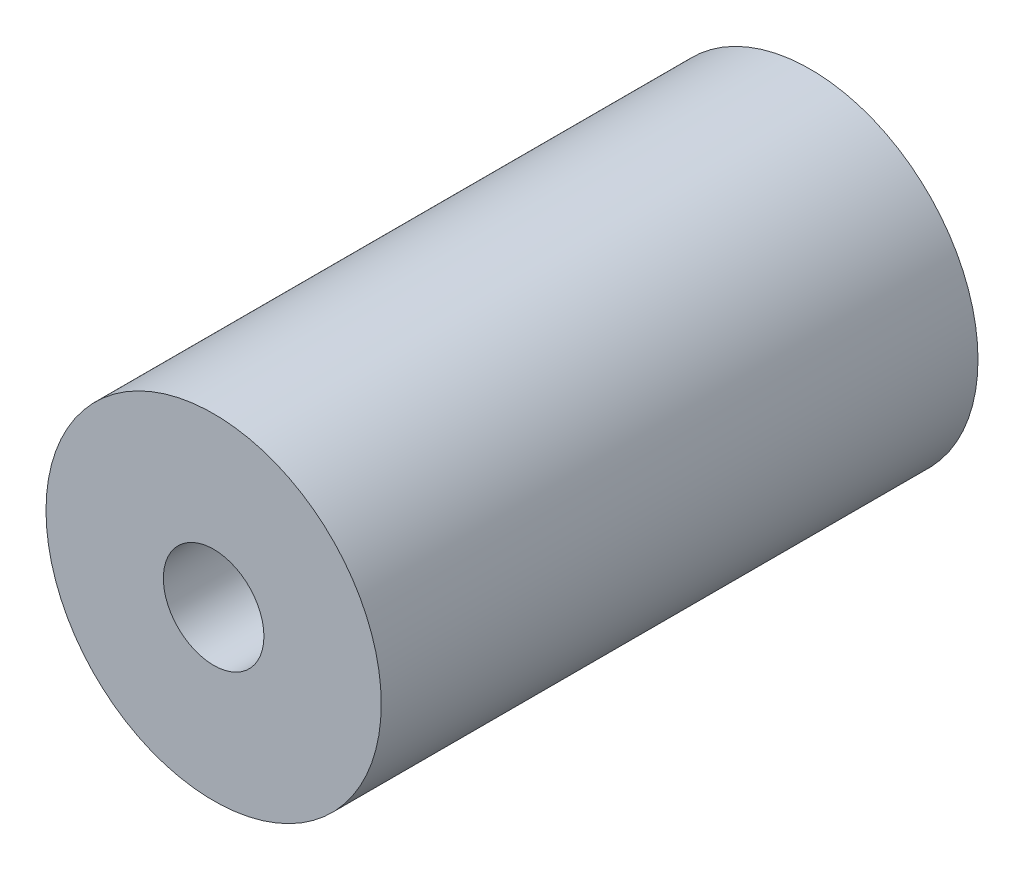
from build123d import *

# Parameters (mm, degrees)
SKETCH1_R                 = 5
BOSS_EXTRUDE1_DEPTH       = 17.8
F_3_0MM_DOWEL_HOLE1_D     = 3
F_3_0MM_DOWEL_HOLE1_DEPTH = 17.8


with BuildPart() as part:
    # Sketch1 → Boss-Extrude1 (new body)
    with BuildSketch(Plane.XY):
        Circle(SKETCH1_R)
    extrude(amount=BOSS_EXTRUDE1_DEPTH)

    # Ø3.0mm Dowel Hole1
    with Locations(Plane.XY.offset(17.8)):
        with Locations((0, 0)):
            Hole(F_3_0MM_DOWEL_HOLE1_D / 2, depth=F_3_0MM_DOWEL_HOLE1_DEPTH)


solid = part.part
